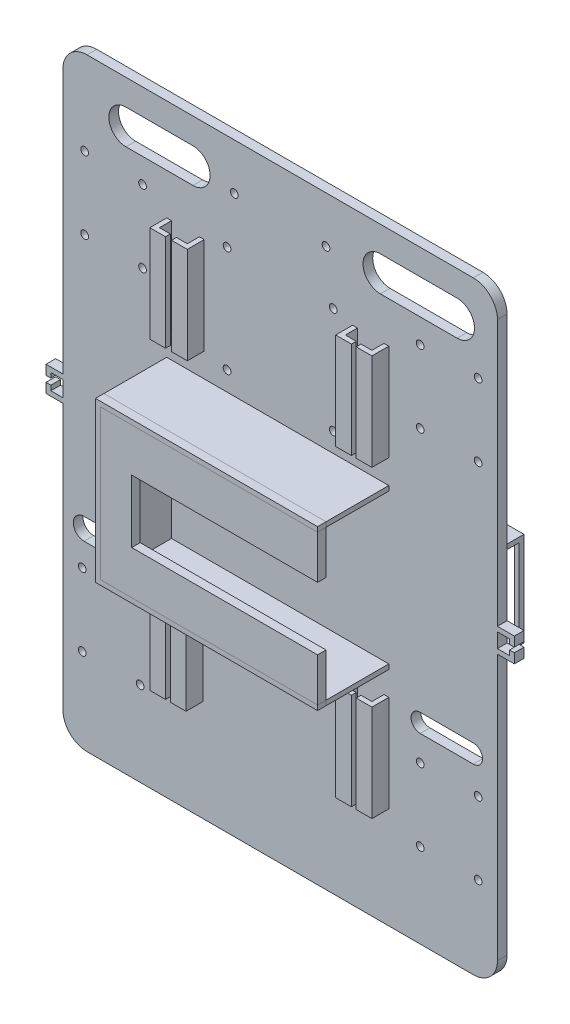
from build123d import *

# Parameters (mm, degrees)
SKETCH_2_R          = 1.6
EXTRUDE_1_DEPTH     = 4
EXTRUDE_2_DEPTH     = 26
SKETCH_5_W          = 13
SKETCH_5_H          = 26
EXTRUDE_3_DEPTH     = 3.5
EXTRUDE_4_DEPTH     = 3.5
SKETCH_7_W          = 2
SKETCH_7_H          = 40
EXTRUDE_5_DEPTH     = 5
SKETCH_8_W          = 6.5
SKETCH_8_H          = 40
EXTRUDE_6_DEPTH     = 2
SKETCH_11_W         = 2
SKETCH_11_H         = 40
EXTRUDE_7_DEPTH     = 5
SKETCH_12_W         = 2
SKETCH_12_H         = 40
EXTRUDE_8_DEPTH     = 5
SKETCH_13_W         = 6.5
SKETCH_13_H         = 40
EXTRUDE_9_DEPTH     = 2
SKETCH_14_W         = 6.5
SKETCH_14_H         = 40
EXTRUDE_10_DEPTH    = 2
SKETCH_16_R         = 1.6
CUT_EXTRUDE_1_DEPTH = 5
SKETCH_20_W         = 35
SKETCH_20_H         = 35
EXTRUDE_12_DEPTH    = 20
SKETCH_21_W         = 18
SKETCH_21_H         = 35
CUT_EXTRUDE_2_DEPTH = 60
SKETCH_22_W         = 3
SKETCH_22_H         = 35
EXTRUDE_13_DEPTH    = 1
SKETCH_23_W         = 3
SKETCH_23_H         = 35
EXTRUDE_18_DEPTH    = 1
SKETCH_24_W         = 39
SKETCH_24_H         = 39
SKETCH_24_W_2       = 35
SKETCH_24_H_2       = 35
EXTRUDE_19_DEPTH    = 20
SKETCH_25_W         = 12
SKETCH_25_H         = 32
CUT_EXTRUDE_3_DEPTH = 50
SKETCH_26_W         = 4
SKETCH_26_H         = 2
EXTRUDE_20_DEPTH    = 5
SKETCH_27_W         = 4
SKETCH_27_H         = 4
EXTRUDE_21_DEPTH    = 2
SKETCH_28_W         = 4
SKETCH_28_H         = 2
EXTRUDE_22_DEPTH    = 5
SKETCH_29_W         = 4
SKETCH_29_H         = 4
EXTRUDE_23_DEPTH    = 2
CUT_EXTRUDE_5_DEPTH = 10
SKETCH_37_R         = 1.6
CUT_EXTRUDE_6_DEPTH = 10
CUT_EXTRUDE_7_DEPTH = 10


with BuildPart() as part:
    # 草图2 → 凸台-拉伸1 (new body)
    with BuildSketch(Plane.XY):
        with BuildLine():
            Line((-97.180739019, 63.077036811), (62.819260981, 63.077036811))
            ThreePointArc((62.819260981, 63.077036811), (69.890328793, 60.148104623), (72.819260981, 53.077036811))
            Line((72.819260981, 53.077036811), (72.819260981, -176.922963189))
            ThreePointArc((72.819260981, -176.922963189), (69.890328793, -183.994031001), (62.819260981, -186.922963189))
            Line((62.819260981, -186.922963189), (-97.180739019, -186.922963189))
            ThreePointArc((-97.180739019, -186.922963189), (-104.251806831, -183.994031001), (-107.180739019, -176.922963189))
            Line((-107.180739019, -176.922963189), (-107.180739019, 53.077036811))
            ThreePointArc((-107.180739019, 53.077036811), (-104.251806831, 60.148104623), (-97.180739019, 63.077036811))
        make_face()
        with Locations((-99.180739019, -151.922963189)):
            Circle(SKETCH_2_R, mode=Mode.SUBTRACT)
        with Locations((-99.180739019, -121.922963189)):
            Circle(SKETCH_2_R, mode=Mode.SUBTRACT)
        with Locations((-75.180739019, -121.922963189)):
            Circle(SKETCH_2_R, mode=Mode.SUBTRACT)
        with Locations((-75.180739019, -151.922963189)):
            Circle(SKETCH_2_R, mode=Mode.SUBTRACT)
        with Locations((64.819260981, -151.922963189)):
            Circle(SKETCH_2_R, mode=Mode.SUBTRACT)
        with Locations((40.819260981, -151.922963189)):
            Circle(SKETCH_2_R, mode=Mode.SUBTRACT)
        with Locations((40.819260981, -121.922963189)):
            Circle(SKETCH_2_R, mode=Mode.SUBTRACT)
        with Locations((64.819260981, -121.922963189)):
            Circle(SKETCH_2_R, mode=Mode.SUBTRACT)
        with Locations((-98.180739019, 28.077036811)):
            Circle(SKETCH_2_R, mode=Mode.SUBTRACT)
        with Locations((-98.180739019, -1.922963189)):
            Circle(SKETCH_2_R, mode=Mode.SUBTRACT)
        with Locations((-74.180739019, 28.077036811)):
            Circle(SKETCH_2_R, mode=Mode.SUBTRACT)
        with Locations((-74.180739019, -1.922963189)):
            Circle(SKETCH_2_R, mode=Mode.SUBTRACT)
        with Locations((40.819260981, 28.077036811)):
            Circle(SKETCH_2_R, mode=Mode.SUBTRACT)
        with Locations((64.819260981, 28.077036811)):
            Circle(SKETCH_2_R, mode=Mode.SUBTRACT)
        with Locations((40.819260981, -1.922963189)):
            Circle(SKETCH_2_R, mode=Mode.SUBTRACT)
        with Locations((64.819260981, -1.922963189)):
            Circle(SKETCH_2_R, mode=Mode.SUBTRACT)
    extrude(amount=EXTRUDE_1_DEPTH)

    # 草图3 → 凸台-拉伸2 (add)
    with BuildSketch(Plane.XY.offset(4)):
        Polygon((27.819260981, -30.922963189), (-62.180739019, -30.922963189), (-62.180739019, -92.922963189), (27.819260981, -92.922963189), (27.819260981, -94.922963189), (-64.180739019, -94.922963189), (-64.180739019, -28.922963189), (27.819260981, -28.922963189), align=None)
    extrude(amount=EXTRUDE_2_DEPTH)

    # 草图7 → 凸台-拉伸5 (add)
    with BuildSketch(Plane.XY.offset(4)):
        with Locations((-63.180739019, -124.922963189)):
            Rectangle(SKETCH_7_W, SKETCH_7_H)
        with Locations((-50.180739019, -124.922963189)):
            Rectangle(SKETCH_7_W, SKETCH_7_H)
        with Locations((13.819260981, -124.922963189)):
            Rectangle(SKETCH_7_W, SKETCH_7_H)
        with Locations((26.819260981, -124.922963189)):
            Rectangle(SKETCH_7_W, SKETCH_7_H)
    extrude(amount=EXTRUDE_5_DEPTH)

    # 草图8 → 凸台-拉伸6 (add)
    with BuildSketch(Plane.XY.offset(9)):
        with Locations((-60.930739019, -124.922963189)):
            Rectangle(SKETCH_8_W, SKETCH_8_H)
        with Locations((-52.430739019, -124.922963189)):
            Rectangle(SKETCH_8_W, SKETCH_8_H)
        with Locations((16.069260981, -124.922963189)):
            Rectangle(SKETCH_8_W, SKETCH_8_H)
        with Locations((24.569260981, -124.922963189)):
            Rectangle(SKETCH_8_W, SKETCH_8_H)
    extrude(amount=EXTRUDE_6_DEPTH)

    # 草图11 → 凸台-拉伸7 (add)
    with BuildSketch(Plane.XY.offset(4)):
        with Locations((-49.648958747, 1.077036811)):
            Rectangle(SKETCH_11_W, SKETCH_11_H)
        with Locations((26.819260981, 1.077036811)):
            Rectangle(SKETCH_11_W, SKETCH_11_H)
        with Locations((13.819260981, 1.077036811)):
            Rectangle(SKETCH_11_W, SKETCH_11_H)
    extrude(amount=EXTRUDE_7_DEPTH)

    # 草图12 → 凸台-拉伸8 (add)
    with BuildSketch(Plane.XY.offset(4)):
        with Locations((-63.180739019, 1.077036811)):
            Rectangle(SKETCH_12_W, SKETCH_12_H)
    extrude(amount=EXTRUDE_8_DEPTH)

    # 草图13 → 凸台-拉伸9 (add)
    with BuildSketch(Plane.XY.offset(9)):
        with Locations((-60.930739019, 1.077036811)):
            Rectangle(SKETCH_13_W, SKETCH_13_H)
    extrude(amount=EXTRUDE_9_DEPTH)

    # 草图14 → 凸台-拉伸10 (add)
    with BuildSketch(Plane.XY.offset(9)):
        with Locations((-51.898958747, 1.077036811)):
            Rectangle(SKETCH_14_W, SKETCH_14_H)
        with Locations((24.569260981, 1.077036811)):
            Rectangle(SKETCH_14_W, SKETCH_14_H)
        with Locations((16.069260981, 1.077036811)):
            Rectangle(SKETCH_14_W, SKETCH_14_H)
    extrude(amount=EXTRUDE_10_DEPTH)

    # 草图16 → 切除-拉伸1 (cut)
    with BuildSketch(Plane(origin=(0, 0, 0), x_dir=(-1, 0, 0), z_dir=(0, 0, -1))):
        with Locations((-4.819260981, 23.077036811)):
            Circle(SKETCH_16_R)
        with Locations((39.180739019, 23.077036811)):
            Circle(SKETCH_16_R)
        with Locations((39.180739019, -20.922963189)):
            Circle(SKETCH_16_R)
        with Locations((-4.819260981, -20.922963189)):
            Circle(SKETCH_16_R)
    extrude(amount=-CUT_EXTRUDE_1_DEPTH, mode=Mode.SUBTRACT)

    # 草图20 → 凸台-拉伸12 (add)
    with BuildSketch(Plane(origin=(0, 0, 0), x_dir=(-1, 0, 0), z_dir=(0, 0, -1))):
        Polygon((-22.819260981, -42.422963189), (-59.819260981, -42.422963189), (-59.819260981, -81.422963189), (-20.819260981, -81.422963189), (-20.819260981, -42.422963189), align=None)
        with Locations((-40.319260981, -61.922963189)):
            Rectangle(SKETCH_20_W, SKETCH_20_H, mode=Mode.SUBTRACT)
    extrude(amount=EXTRUDE_12_DEPTH)

    # 草图21 → 切除-拉伸2 (cut)
    with BuildSketch(Plane.ZY.offset(-20.819260981)):
        with Locations((-9, -61.922963189)):
            Rectangle(SKETCH_21_W, SKETCH_21_H)
    extrude(amount=-CUT_EXTRUDE_2_DEPTH, mode=Mode.SUBTRACT)

    # 草图22 → 凸台-拉伸13 (add)
    with BuildSketch(Plane(origin=(59.819260981, 0, 0), x_dir=(0, 0, -1), z_dir=(1, 0, 0))):
        with Locations((1.5, -61.922963189)):
            Rectangle(SKETCH_22_W, SKETCH_22_H)
    extrude(amount=-EXTRUDE_13_DEPTH)

    # 草图23 → 凸台-拉伸18 (add)
    with BuildSketch(Plane.ZY.offset(-20.819260981)):
        with Locations((-1.5, -61.922963189)):
            Rectangle(SKETCH_23_W, SKETCH_23_H)
    extrude(amount=-EXTRUDE_18_DEPTH)

    # 草图24 → 凸台-拉伸19 (add)
    with BuildSketch(Plane(origin=(0, 0, 0), x_dir=(-1, 0, 0), z_dir=(0, 0, -1))):
        with Locations((74.313659909, -61.922963189)):
            Rectangle(SKETCH_24_W, SKETCH_24_H)
        with Locations((74.680739019, -61.922963189)):
            Rectangle(SKETCH_24_W_2, SKETCH_24_H_2, mode=Mode.SUBTRACT)
    extrude(amount=EXTRUDE_19_DEPTH)

    # 草图25 → 切除-拉伸3 (cut)
    with BuildSketch(Plane.ZY.offset(93.813659909)):
        with Locations((-9, -60.422963189)):
            Rectangle(SKETCH_25_W, SKETCH_25_H)
    extrude(amount=-CUT_EXTRUDE_3_DEPTH, mode=Mode.SUBTRACT)

    # 草图26 → 凸台-拉伸20 (add)
    with BuildSketch(Plane(origin=(72.819260981, 0, 0), x_dir=(0, 0, -1), z_dir=(1, 0, 0))):
        with Locations((-2, -57.922963189)):
            Rectangle(SKETCH_26_W, SKETCH_26_H)
        with Locations((-2, -65.922963189)):
            Rectangle(SKETCH_26_W, SKETCH_26_H)
    extrude(amount=EXTRUDE_20_DEPTH)

    # 草图27 → 凸台-拉伸21 (add)
    with BuildSketch(Plane(origin=(77.819260981, 0, 0), x_dir=(0, 0, -1), z_dir=(1, 0, 0))):
        with Locations((-2, -58.922963189)):
            Rectangle(SKETCH_27_W, SKETCH_27_H)
        with Locations((-2, -64.922963189)):
            Rectangle(SKETCH_27_W, SKETCH_27_H)
    extrude(amount=EXTRUDE_21_DEPTH)

    # 草图28 → 凸台-拉伸22 (add)
    with BuildSketch(Plane.ZY.offset(107.180739019)):
        with Locations((2, -57.402028862)):
            Rectangle(SKETCH_28_W, SKETCH_28_H)
        with Locations((2, -65.922963189)):
            Rectangle(SKETCH_28_W, SKETCH_28_H)
    extrude(amount=EXTRUDE_22_DEPTH)

    # 草图29 → 凸台-拉伸23 (add)
    with BuildSketch(Plane.ZY.offset(112.180739019)):
        with Locations((2, -58.402028862)):
            Rectangle(SKETCH_29_W, SKETCH_29_H)
        with Locations((2, -64.922963189)):
            Rectangle(SKETCH_29_W, SKETCH_29_H)
    extrude(amount=EXTRUDE_23_DEPTH)

    # 草图34 → 切除-拉伸5 (cut)
    with BuildSketch(Plane.XY.offset(4)):
        with BuildLine():
            Line((-98.419988723, -103.107592322), (-76.25776255, -103.107592322))
            ThreePointArc((-76.25776255, -103.107592322), (-71.799089829, -107.566265043), (-76.25776255, -112.024937764))
            Line((-76.25776255, -112.024937764), (-98.419988723, -112.024937764))
            ThreePointArc((-98.419988723, -112.024937764), (-102.878661444, -107.566265043), (-98.419988723, -103.107592322))
        make_face()
        with BuildLine():
            Line((40.829127173, -103.772257764), (62.840428219, -103.772257764))
            ThreePointArc((62.840428219, -103.772257764), (66.634435498, -107.566265043), (62.840428219, -111.360272322))
            Line((62.840428219, -111.360272322), (40.829127173, -111.360272322))
            ThreePointArc((40.829127173, -111.360272322), (37.035119894, -107.566265043), (40.829127173, -103.772257764))
        make_face()
    extrude(amount=-CUT_EXTRUDE_5_DEPTH, mode=Mode.SUBTRACT)

    # 草图37 → 切除-拉伸6 (cut)
    with BuildSketch(Plane(origin=(0, 0, 0), x_dir=(-1, 0, 0), z_dir=(0, 0, -1))):
        with Locations((-1.819260981, 43.866786324)):
            Circle(SKETCH_37_R)
        with Locations((36.180739019, 43.866786324)):
            Circle(SKETCH_37_R)
    extrude(amount=-CUT_EXTRUDE_6_DEPTH, mode=Mode.SUBTRACT)

    # 草图40 → 切除-拉伸7 (cut)
    with BuildSketch(Plane(origin=(0, 0, 0), x_dir=(-1, 0, 0), z_dir=(0, 0, -1))):
        with BuildLine():
            Line((-56.117565277, 52.456382464), (-24.335097021, 52.456382464))
            ThreePointArc((-24.335097021, 52.456382464), (-17.151388442, 45.272673886), (-24.335097021, 38.088965308))
            Line((-24.335097021, 38.088965308), (-56.117565277, 38.088965308))
            ThreePointArc((-56.117565277, 38.088965308), (-63.301273855, 45.272673886), (-56.117565277, 52.456382464))
        make_face()
        with BuildLine():
            Line((53.317311688, 52.387776294), (81.037636117, 52.387776294))
            ThreePointArc((81.037636117, 52.387776294), (88.152738525, 45.272673886), (81.037636117, 38.157571478))
            Line((81.037636117, 38.157571478), (53.317311688, 38.157571478))
            ThreePointArc((53.317311688, 38.157571478), (46.20220928, 45.272673886), (53.317311688, 52.387776294))
        make_face()
    extrude(amount=-CUT_EXTRUDE_7_DEPTH, mode=Mode.SUBTRACT)


with BuildPart() as body_2:
    # 草图5 → 凸台-拉伸3 (new body)
    with BuildSketch(Plane.XY.offset(30)):
        Polygon((27.819260981, -48.922963189), (27.819260981, -30.922963189), (-62.180739019, -30.922963189), (-62.180739019, -48.922963189), (-49.180739019, -48.922963189), align=None)
        Polygon((27.819260981, -74.922963189), (-49.180739019, -74.922963189), (-62.180739019, -74.922963189), (-62.180739019, -92.922963189), (27.819260981, -92.922963189), align=None)
        with Locations((-55.680739019, -61.922963189)):
            Rectangle(SKETCH_5_W, SKETCH_5_H)
    extrude(amount=EXTRUDE_3_DEPTH)


with BuildPart() as body_3:
    # 草图6 → 凸台-拉伸4 (new body)
    with BuildSketch(Plane.XY.offset(33.5)):
        Polygon((27.819260981, -30.922963189), (27.819260981, -28.922963189), (-64.180739019, -28.922963189), (-64.180739019, -94.922963189), (27.819260981, -94.922963189), (27.819260981, -92.922963189), (-62.180739019, -92.922963189), (-62.180739019, -30.922963189), align=None)
    extrude(amount=-EXTRUDE_4_DEPTH)


solid = Compound([part.part, body_2.part, body_3.part])
